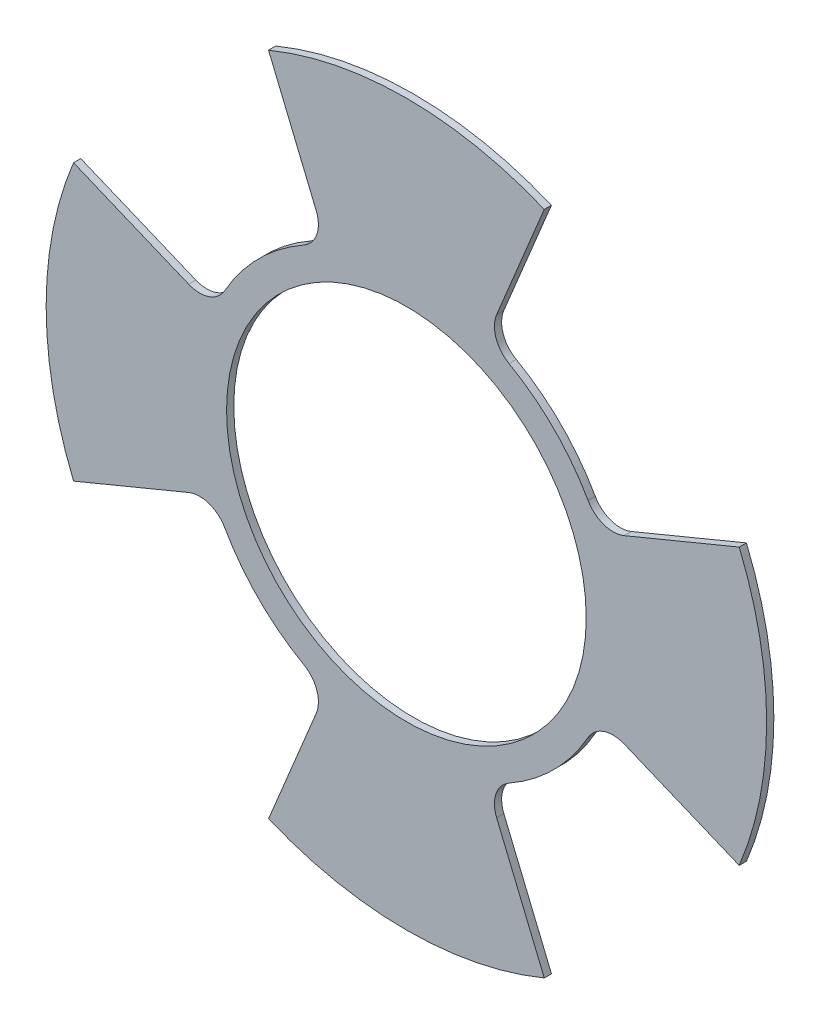
from build123d import *

# Parameters (mm, degrees)
SKETCH1_R                = 79.375
SKETCH1_R_2              = 39.624
BOSS_EXTRUDE1_DEPTH      = 1.5875
SKETCH2_R                = 79.375
SKETCH2_R_2              = 45.974
CUT_EXTRUDE1_DEPTH       = 2.5875
BOSS_EXTRUDE2_DEPTH      = 1.5875
FILLET1_R                = 6.35
CIRPATTERN1_COUNT        = 4
FILLET1_OF_CIRPATTERN1_R = 6.35


with BuildPart() as part:
    # Sketch1 → Boss-Extrude1 (new body)
    with BuildSketch(Plane.XY):
        Circle(SKETCH1_R)
        Circle(SKETCH1_R_2, mode=Mode.SUBTRACT)
    extrude(amount=BOSS_EXTRUDE1_DEPTH)

    # Sketch2 → Cut-Extrude1 (cut, through all)
    with BuildSketch(Plane.XY.offset(1.5875)):
        Circle(SKETCH2_R)
        Circle(SKETCH2_R_2, mode=Mode.SUBTRACT)
    extrude(amount=-CUT_EXTRUDE1_DEPTH, mode=Mode.SUBTRACT)

    # Sketch3 → Boss-Extrude2 (add)
    with BuildSketch(Plane.XY.offset(1.5875)):
        with BuildLine():
            ThreePointArc((30.375497444, 73.332937893), (0, 79.375), (-30.375497444, 73.332937893))
            Line((-30.375497444, 73.332937893), (-17.59348812, 42.474437628))
            ThreePointArc((-17.59348812, 42.474437628), (0, 45.974), (17.59348812, 42.474437628))
            Line((17.59348812, 42.474437628), (30.375497444, 73.332937893))
        make_face()
    boss_extrude2 = extrude(amount=-BOSS_EXTRUDE2_DEPTH)

    # Fillet1
    fillet1_edges = [part.edges().sort_by_distance(p)[0] for p in [
        (17.59348812, 42.474437628, 0.79375),
        (-17.59348812, 42.474437628, 0.79375),
    ]]
    fillet(fillet1_edges, radius=FILLET1_R)

    # CirPattern1: Boss-Extrude2 ×4 about axis
    cirpattern1_axis = Axis((0, 0, 0), (0, 0, 1))
    for i in range(1, CIRPATTERN1_COUNT):
        add(boss_extrude2.rotate(cirpattern1_axis, i * 360 / CIRPATTERN1_COUNT))

    # Fillet1 of CirPattern1
    fillet1_of_cirpattern1_edges = [part.edges().sort_by_distance(p)[0] for p in [
        (-42.474437628, 17.59348812, 0.79375),
        (-42.474437628, -17.59348812, 0.79375),
        (-17.59348812, -42.474437628, 0.79375),
        (17.59348812, -42.474437628, 0.79375),
        (42.474437628, -17.59348812, 0.79375),
        (42.474437628, 17.59348812, 0.79375),
    ]]
    fillet(fillet1_of_cirpattern1_edges, radius=FILLET1_OF_CIRPATTERN1_R)


solid = part.part
